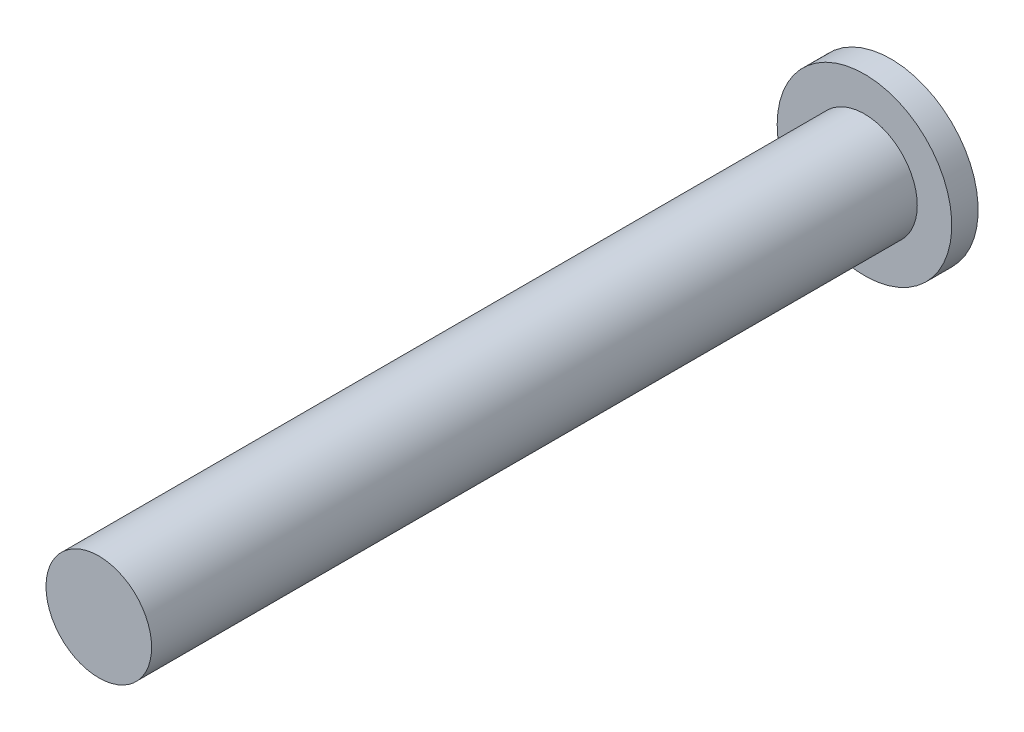
from build123d import *

# Parameters (mm, degrees)
SKETCH1_R           = 4
BOSS_EXTRUDE1_DEPTH = 58
SKETCH2_R           = 6.613243833
BOSS_EXTRUDE2_DEPTH = 2


with BuildPart() as part:
    # Sketch1 → Boss-Extrude1 (new body)
    with BuildSketch(Plane(origin=(0, 0, 28), x_dir=(-1, 0, 0), z_dir=(0, 0, -1))):
        with Locations((17.5, 6.122498999)):
            Circle(SKETCH1_R)
    extrude(amount=BOSS_EXTRUDE1_DEPTH)

    # Sketch2 → Boss-Extrude2 (add)
    with BuildSketch(Plane(origin=(0, 0, -30), x_dir=(-1, 0, 0), z_dir=(0, 0, -1))):
        with Locations((17.5, 6.122498999)):
            Circle(SKETCH2_R)
    extrude(amount=BOSS_EXTRUDE2_DEPTH)


solid = part.part
